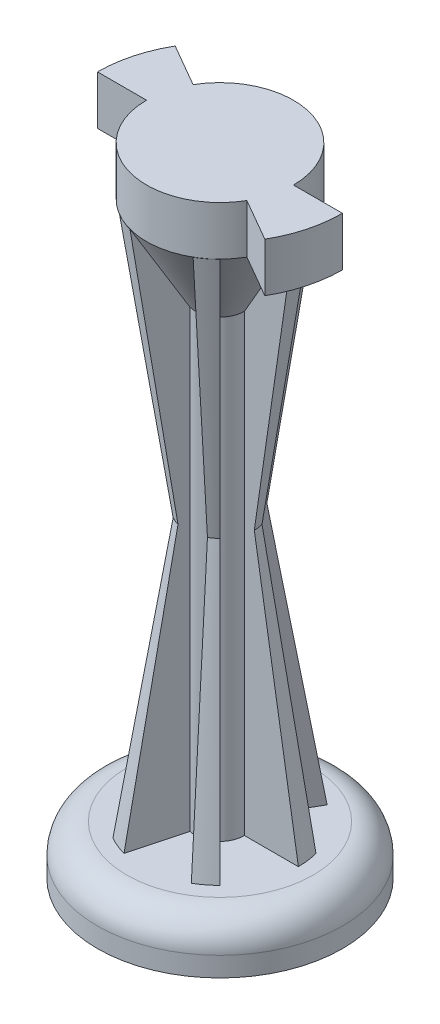
from build123d import *

# Parameters (mm, degrees)
SKETCH1_R           = 12.5
BOSS_EXTRUDE1_DEPTH = 5
SKETCH2_R           = 2.5
BOSS_EXTRUDE2_DEPTH = 60
BOSS_EXTRUDE3_DEPTH = 5
REVOLVE1_ANGLE      = 15
SKETCH7_R           = 7.5
BOSS_EXTRUDE4_DEPTH = 5
CIRPATTERN1_COUNT   = 6
FILLET1_R           = 3
SKETCH8_R           = 7.5
BOSS_EXTRUDE5_DEPTH = 10
BOSS_EXTRUDE5_TAPER = 30


with BuildPart() as part:
    # Sketch1 → Boss-Extrude1 (new body)
    with BuildSketch(Plane(origin=(0, 0, 0), x_dir=(1, 0, 0), z_dir=(0, 1, 0))):
        Circle(SKETCH1_R)
    extrude(amount=BOSS_EXTRUDE1_DEPTH)

    # Sketch2 → Boss-Extrude2 (add)
    with BuildSketch(Plane(origin=(0, 5, 0), x_dir=(1, 0, 0), z_dir=(0, 1, 0))):
        Circle(SKETCH2_R)
    extrude(amount=BOSS_EXTRUDE2_DEPTH)

    # Sketch3 → Boss-Extrude3 (add)
    with BuildSketch(Plane(origin=(0, 65, 0), x_dir=(1, 0, 0), z_dir=(0, 1, 0))):
        with BuildLine():
            Line((2.5, 0), (12.5, 0))
            ThreePointArc((12.5, 0), (12.074072829, -3.235238064), (10.825317547, -6.25))
            Line((10.825317547, -6.25), (2.165063509, -1.25))
            ThreePointArc((2.165063509, -1.25), (-0.647047613, -2.414814566), (-2.5, 0))
            Line((-2.5, 0), (-12.5, 0))
            ThreePointArc((-12.5, 0), (-12.074072829, 3.235238064), (-10.825317547, 6.25))
            Line((-10.825317547, 6.25), (-2.165063509, 1.25))
            ThreePointArc((-2.165063509, 1.25), (0.647047613, 2.414814566), (2.5, 0))
        make_face()
    extrude(amount=-BOSS_EXTRUDE3_DEPTH)

    # Sketch6 → Revolve1 (revolve)
    with BuildSketch(Plane.XY):
        Polygon((8, 5), (3.5, 32.491106736), (7.5, 59.982213472), (0, 59.982213472), (0, 5), align=None)
    revolve1 = revolve(axis=Axis((0, 5, 0), (0, 1, 0)), revolution_arc=REVOLVE1_ANGLE)

    # Sketch7 → Boss-Extrude4 (add)
    with BuildSketch(Plane(origin=(0, 65, 0), x_dir=(1, 0, 0), z_dir=(0, 1, 0))):
        Circle(SKETCH7_R)
    extrude(amount=-BOSS_EXTRUDE4_DEPTH)

    # CirPattern1: Revolve1 ×6 about axis
    cirpattern1_axis = Axis((0, 0, 0), (0, 1, 0))
    for i in range(1, CIRPATTERN1_COUNT):
        add(revolve1.rotate(cirpattern1_axis, i * 360 / CIRPATTERN1_COUNT))

    # Fillet1
    fillet1_edges = [part.edges().sort_by_distance(p)[0] for p in [
        (-12.5, 5, 0),
    ]]
    fillet(fillet1_edges, radius=FILLET1_R)

    # Sketch8 → Boss-Extrude5 (add)
    with BuildSketch(Plane(origin=(0, 60, 0), x_dir=(-1, 0, 0), z_dir=(0, -1, 0))):
        Circle(SKETCH8_R)
    extrude(amount=BOSS_EXTRUDE5_DEPTH, taper=BOSS_EXTRUDE5_TAPER)


solid = part.part
